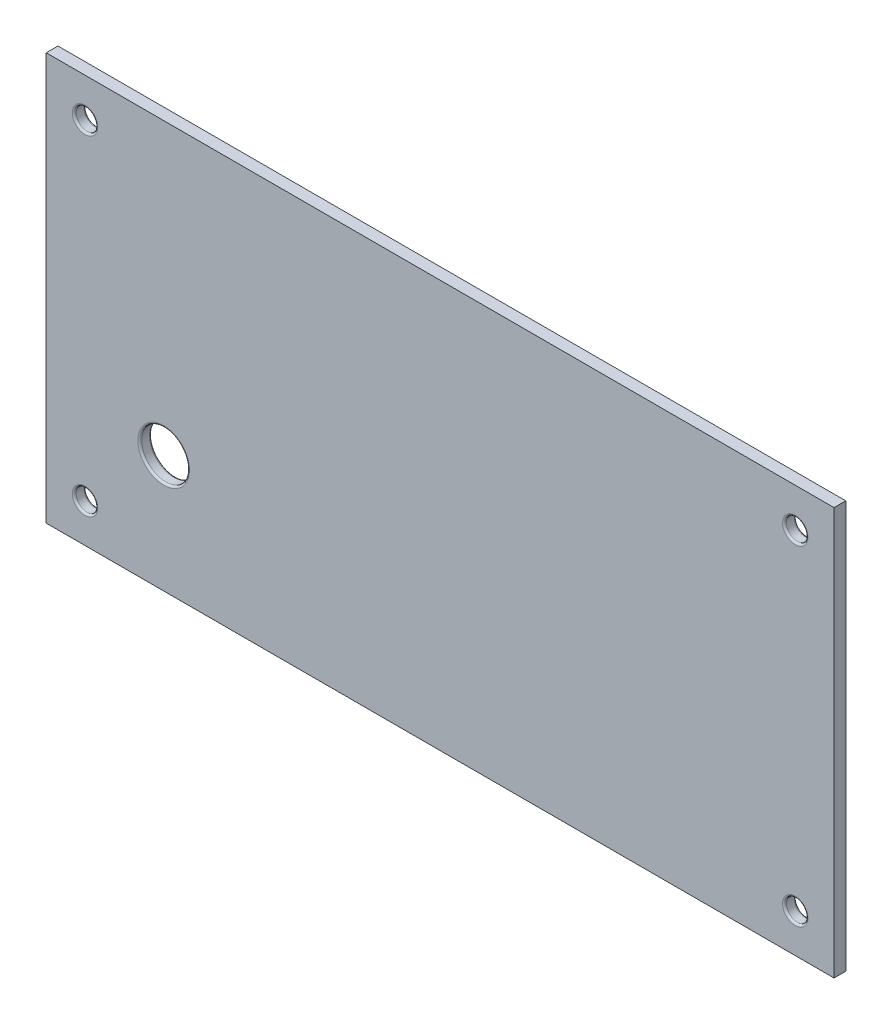
from build123d import *

# Parameters (mm, degrees)
SKETCH1_W           = 201.204
SKETCH1_H           = 104.04
BOSS_EXTRUDE1_DEPTH = 3
SKETCH3_R           = 2.75
CUT_EXTRUDE2_DEPTH  = 4
FILLET2_R           = 0.5
SKETCH4_R           = 6.1
CUT_EXTRUDE4_DEPTH  = 4
FILLET3_R           = 0.5


with BuildPart() as part:
    # Sketch1 → Boss-Extrude1 (new body)
    with BuildSketch(Plane.XY):
        Rectangle(SKETCH1_W, SKETCH1_H)
    extrude(amount=BOSS_EXTRUDE1_DEPTH)

    # Sketch3 → Cut-Extrude2 (cut, through all)
    with BuildSketch(Plane.XY.offset(3)):
        with Locations((-90.702, 42.12)):
            Circle(SKETCH3_R)
        with Locations((90.702, 42.12)):
            Circle(SKETCH3_R)
        with Locations((90.702, -42.12)):
            Circle(SKETCH3_R)
        with Locations((-90.702, -42.12)):
            Circle(SKETCH3_R)
    extrude(amount=-CUT_EXTRUDE2_DEPTH, mode=Mode.SUBTRACT)

    # Fillet2
    fillet2_edges = [part.edges().sort_by_distance(p)[0] for p in [
        (-93.452, -42.12, 0),
        (-93.452, -42.12, 3),
        (87.952, -42.12, 0),
        (87.952, -42.12, 3),
        (87.952, 42.12, 0),
        (87.952, 42.12, 3),
        (-93.452, 42.12, 0),
        (-93.452, 42.12, 3),
    ]]
    fillet(fillet2_edges, radius=FILLET2_R)

    # Sketch4 → Cut-Extrude4 (cut, through all)
    with BuildSketch(Plane.XY.offset(3)):
        with Locations((-70.602, -22.02)):
            Circle(SKETCH4_R)
    extrude(amount=-CUT_EXTRUDE4_DEPTH, mode=Mode.SUBTRACT)

    # Fillet3
    fillet3_edges = [part.edges().sort_by_distance(p)[0] for p in [
        (-76.702, -22.02, 0),
        (-76.702, -22.02, 3),
    ]]
    fillet(fillet3_edges, radius=FILLET3_R)


solid = part.part
